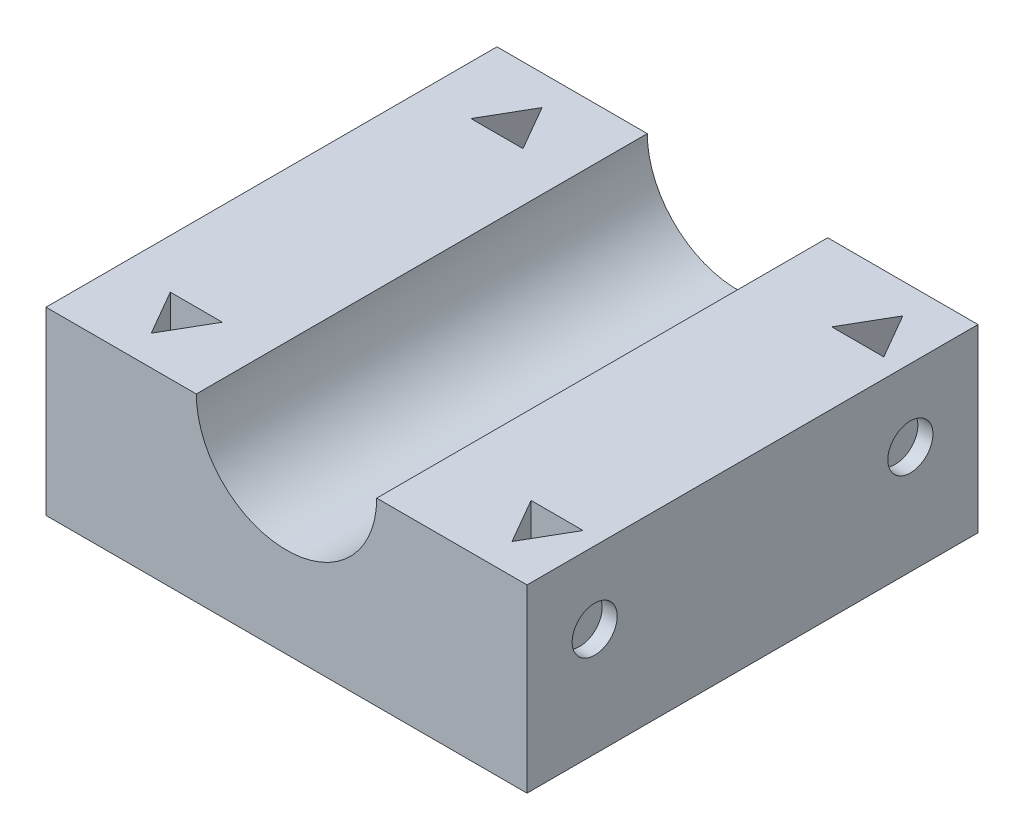
from build123d import *

# Parameters (mm, degrees)
BOSS_EXTRUDE1_DEPTH = 30
CUT_EXTRUDE1_DEPTH  = 13
SKETCH5_R           = 1.5
CUT_EXTRUDE2_DEPTH  = 1
SKETCH6_R           = 1.5
CUT_EXTRUDE3_DEPTH  = 1


with BuildPart() as part:
    # Sketch1 → Boss-Extrude1 (new body)
    with BuildSketch(Plane.XY):
        with BuildLine():
            Line((0, 0), (0, 12))
            Line((0, 12), (10, 12))
            ThreePointArc((10, 12), (16, 6), (22, 12))
            Line((22, 12), (32, 12))
            Line((32, 12), (32, 0))
            Line((32, 0), (0, 0))
        make_face()
    extrude(amount=BOSS_EXTRUDE1_DEPTH)

    # Sketch4 → Cut-Extrude1 (cut, through all)
    with BuildSketch(Plane(origin=(0, 12, 0), x_dir=(1, 0, 0), z_dir=(0, 1, 0))):
        Polygon((5, -2), (3.267949192, -5), (6.732050808, -5), align=None)
        Polygon((5, -28), (6.732050808, -25), (3.267949192, -25), align=None)
        Polygon((29, -28), (30.732050808, -25), (27.267949192, -25), align=None)
        Polygon((29, -2), (27.267949192, -5), (30.732050808, -5), align=None)
    extrude(amount=-CUT_EXTRUDE1_DEPTH, mode=Mode.SUBTRACT)

    # Sketch5 → Cut-Extrude2 (cut)
    with BuildSketch(Plane(origin=(32, 0, 0), x_dir=(0, 0, -1), z_dir=(1, 0, 0))):
        with Locations((-25.5, 7.2)):
            Circle(SKETCH5_R)
        with Locations((-4.5, 7.2)):
            Circle(SKETCH5_R)
    extrude(amount=-CUT_EXTRUDE2_DEPTH, mode=Mode.SUBTRACT)

    # Sketch6 → Cut-Extrude3 (cut)
    with BuildSketch(Plane.ZY):
        with Locations((4.5, 7.661165518)):
            Circle(SKETCH6_R)
        with Locations((25.5, 7.661165518)):
            Circle(SKETCH6_R)
    extrude(amount=-CUT_EXTRUDE3_DEPTH, mode=Mode.SUBTRACT)


solid = part.part
